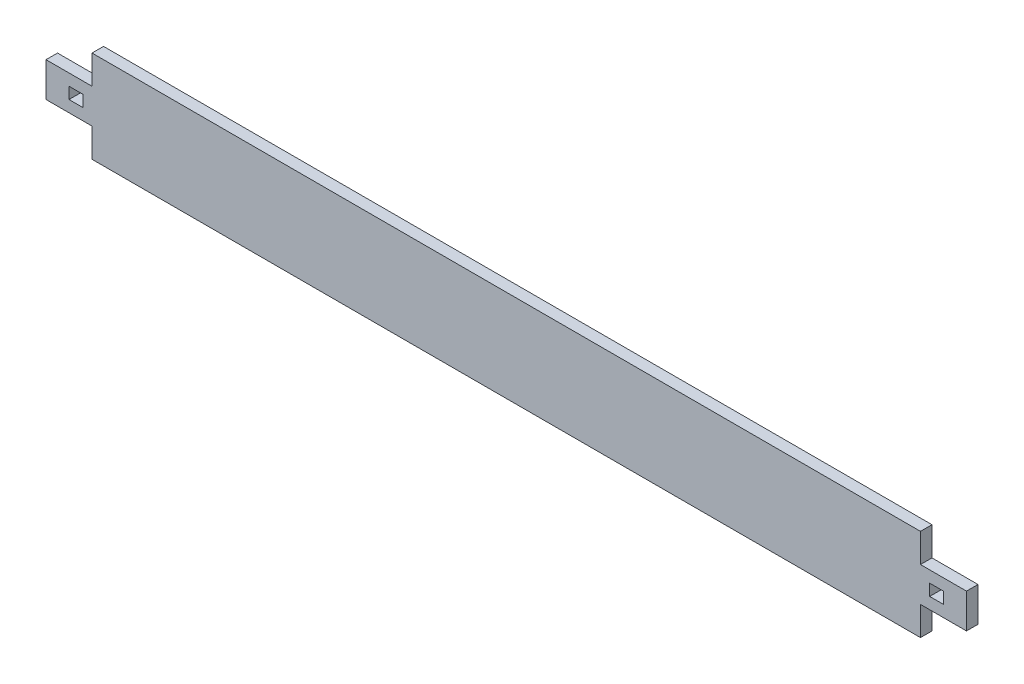
from build123d import *

# Parameters (mm, degrees)
SKETCH1_W           = 457.2
SKETCH1_H           = 50.8
BOSS_EXTRUDE1_DEPTH = 6.35
SKETCH2_W           = 50.8
SKETCH2_H           = 19.05
BOSS_EXTRUDE2_DEPTH = 6.35
SKETCH3_W           = 7.62
SKETCH3_H           = 6.35
CUT_EXTRUDE1_DEPTH  = 7.35


with BuildPart() as part:
    # Sketch1 → Boss-Extrude1 (new body)
    with BuildSketch(Plane.XY):
        Rectangle(SKETCH1_W, SKETCH1_H)
    extrude(amount=BOSS_EXTRUDE1_DEPTH)

    # Sketch2 → Boss-Extrude2 (add)
    with BuildSketch(Plane.XY.offset(6.35)):
        with Locations((-228.6, 0)):
            Rectangle(SKETCH2_W, SKETCH2_H)
    boss_extrude2 = extrude(amount=-BOSS_EXTRUDE2_DEPTH)

    # Sketch3 → Cut-Extrude1 (cut, through all)
    with BuildSketch(Plane.XY.offset(6.35)):
        with Locations((-237.49, 0)):
            Rectangle(SKETCH3_W, SKETCH3_H)
    cut_extrude1 = extrude(amount=-CUT_EXTRUDE1_DEPTH, mode=Mode.SUBTRACT)

    # Mirror1: Boss-Extrude2, Cut-Extrude1 across plane
    add(boss_extrude2.mirror(Plane(origin=(0, 0, 0), x_dir=(0, 0, 1), z_dir=(1, 0, 0))))
    add(cut_extrude1.mirror(Plane(origin=(0, 0, 0), x_dir=(0, 0, 1), z_dir=(1, 0, 0))), mode=Mode.SUBTRACT)


solid = part.part
